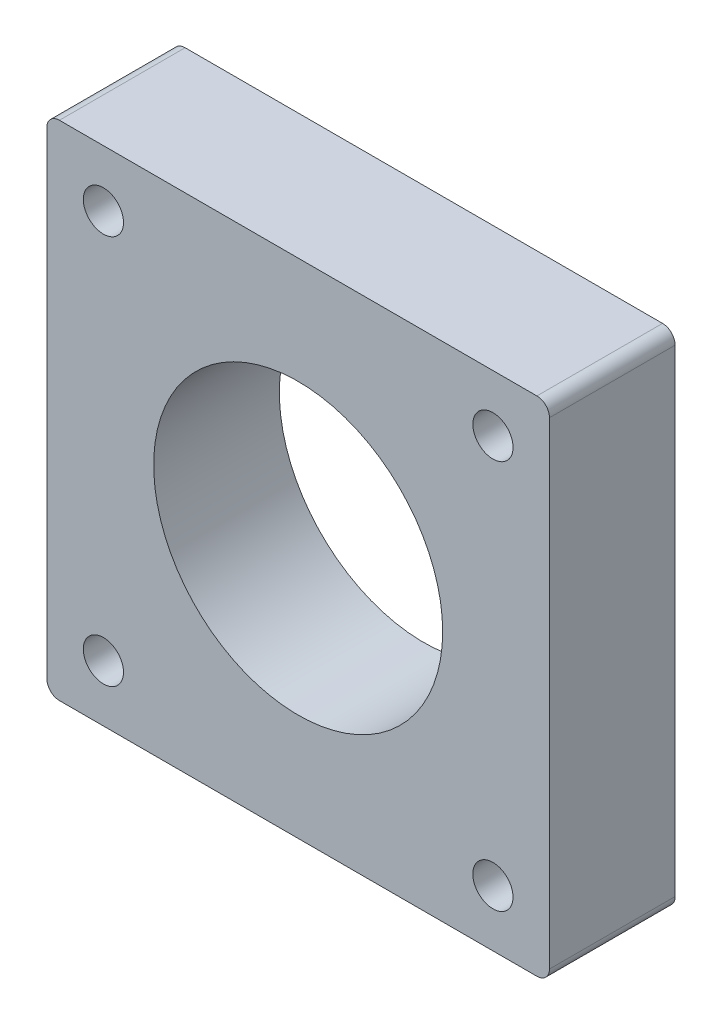
from build123d import *

# Parameters (mm, degrees)
SKETCH1_R           = 11.5
SKETCH1_R_2         = 1.6
BOSS_EXTRUDE1_DEPTH = 10


with BuildPart() as part:
    # Sketch1 → Boss-Extrude1 (new body)
    with BuildSketch(Plane.XY):
        with BuildLine():
            Line((-20, 19), (-20, -19))
            ThreePointArc((-20, -19), (-19.707106781, -19.707106781), (-19, -20))
            Line((-19, -20), (19, -20))
            ThreePointArc((19, -20), (19.707106781, -19.707106781), (20, -19))
            Line((20, -19), (20, 19))
            ThreePointArc((20, 19), (19.707106781, 19.707106781), (19, 20))
            Line((19, 20), (-19, 20))
            ThreePointArc((-19, 20), (-19.707106781, 19.707106781), (-20, 19))
        make_face()
        Circle(SKETCH1_R, mode=Mode.SUBTRACT)
        with Locations((-15.5, 15.5)):
            Circle(SKETCH1_R_2, mode=Mode.SUBTRACT)
        with Locations((15.5, 15.5)):
            Circle(SKETCH1_R_2, mode=Mode.SUBTRACT)
        with Locations((15.5, -15.5)):
            Circle(SKETCH1_R_2, mode=Mode.SUBTRACT)
        with Locations((-15.5, -15.5)):
            Circle(SKETCH1_R_2, mode=Mode.SUBTRACT)
    extrude(amount=BOSS_EXTRUDE1_DEPTH)


solid = part.part
